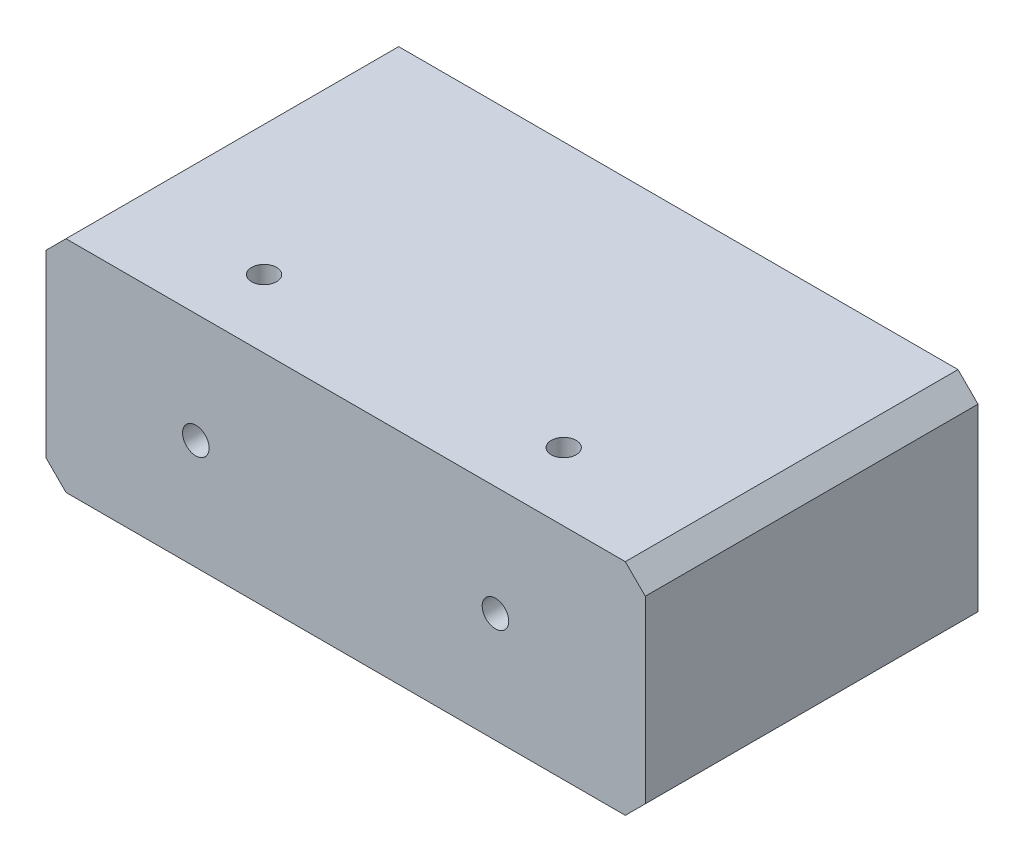
from build123d import *

# Parameters (mm, degrees)
SKETCH1_W                              = 152.4
SKETCH1_H                              = 84.6074
EXTRUDE1_DEPTH                         = 55.88
TAPPED_HOLE_FOR_1_4_20_HELICOIL1_D     = 6.7564
TAPPED_HOLE_FOR_1_4_20_HELICOIL1_DEPTH = 19.685
TAPPED_HOLE_FOR_1_4_20_HELICOIL1_TIP   = 2.029827343
F_1_4_0_25_DIAMETER_HOLE1_D            = 6.35
F_1_4_0_25_DIAMETER_HOLE1_DEPTH        = 27.94
F_1_4_0_25_DIAMETER_HOLE1_TIP          = 1.907732465
CHAMFER1_SIZE                          = 5.08


with BuildPart() as part:
    # Sketch1 → Extrude1 (new body)
    with BuildSketch(Plane(origin=(0, 0, 0), x_dir=(1, 0, 0), z_dir=(0, 1, 0))):
        Rectangle(SKETCH1_W, SKETCH1_H)
    extrude(amount=EXTRUDE1_DEPTH)

    # Tapped Hole for 1/4-20 Helicoil1
    with Locations(Plane.XY.offset(42.3037)):
        with Locations((-38.1, 27.94), (38.1, 27.94)):
            Hole(TAPPED_HOLE_FOR_1_4_20_HELICOIL1_D / 2, depth=TAPPED_HOLE_FOR_1_4_20_HELICOIL1_DEPTH)
            with Locations((0, 0, -(TAPPED_HOLE_FOR_1_4_20_HELICOIL1_DEPTH + TAPPED_HOLE_FOR_1_4_20_HELICOIL1_TIP / 2))):  # 118° drill point
                Cone(0, TAPPED_HOLE_FOR_1_4_20_HELICOIL1_D / 2, TAPPED_HOLE_FOR_1_4_20_HELICOIL1_TIP, mode=Mode.SUBTRACT)

    # 1/4 (0.25) Diameter Hole1
    with Locations(Plane(origin=(0, 55.88, 0), x_dir=(-1, 0, 0), z_dir=(0, 1, 0))):
        with Locations((-38.160987939, 25.011375754), (38.039012061, 25.011375754)):
            Hole(F_1_4_0_25_DIAMETER_HOLE1_D / 2, depth=F_1_4_0_25_DIAMETER_HOLE1_DEPTH)
            with Locations((0, 0, -(F_1_4_0_25_DIAMETER_HOLE1_DEPTH + F_1_4_0_25_DIAMETER_HOLE1_TIP / 2))):  # 118° drill point
                Cone(0, F_1_4_0_25_DIAMETER_HOLE1_D / 2, F_1_4_0_25_DIAMETER_HOLE1_TIP, mode=Mode.SUBTRACT)

    # Chamfer1
    chamfer1_edges = [part.edges().sort_by_distance(p)[0] for p in [
        (76.2, 55.88, 0),
        (-76.2, 55.88, 0),
        (76.2, 0, 0),
        (-76.2, 0, 0),
    ]]
    chamfer(chamfer1_edges, length=CHAMFER1_SIZE)


solid = part.part
